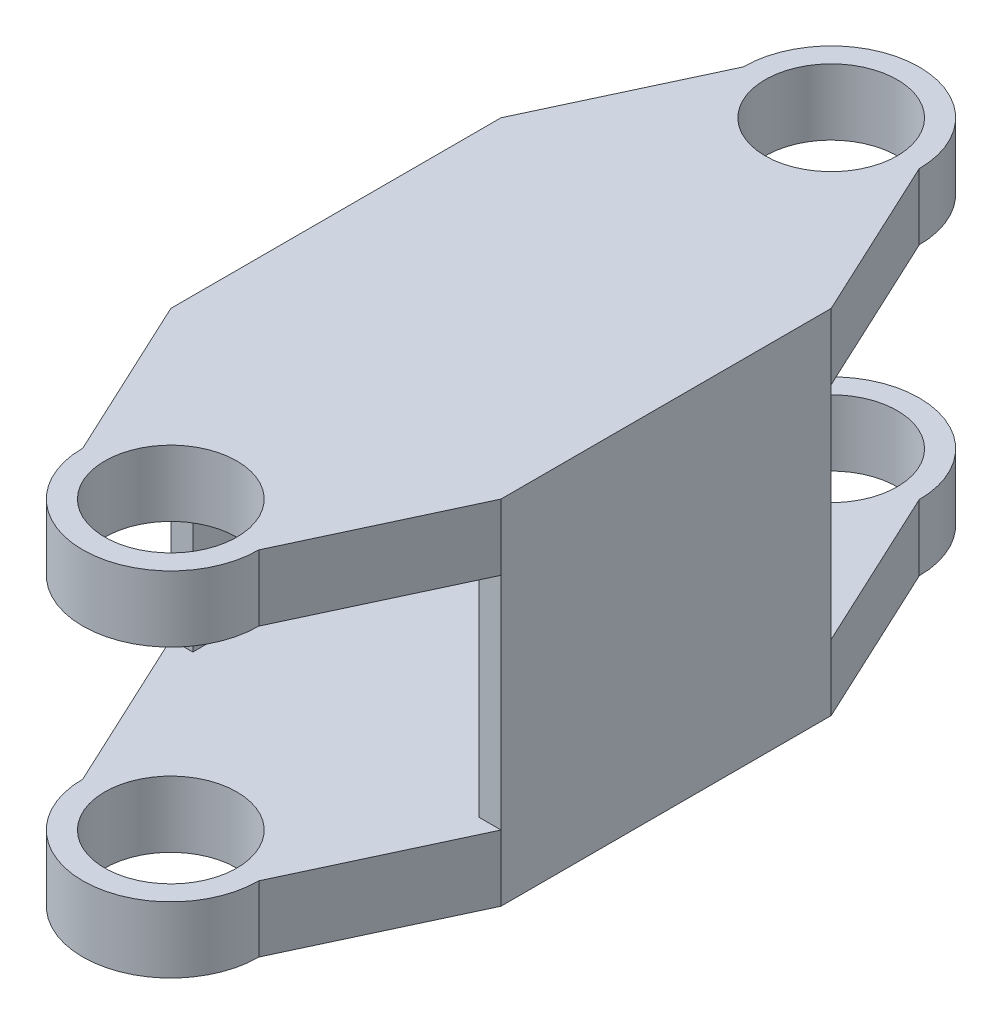
from build123d import *

# Parameters (mm, degrees)
SKETCH1_R           = 3
BOSS_EXTRUDE1_DEPTH = 3
SKETCH5_W           = 1
SKETCH5_H           = 15
SKETCH4_W           = 1
SKETCH4_H           = 15
SKETCH7_W           = 1
SKETCH7_H           = 15
SKETCH6_W           = 1
SKETCH6_H           = 15


with BuildPart() as part:
    # Sketch1 → Boss-Extrude1 (new body)
    with BuildSketch(Plane(origin=(0, 5.01, 0), x_dir=(1, 0, 0), z_dir=(0, 1, 0))):
        with BuildLine():
            Line((-7.5, -7.5), (-7.5, 7.5))
            Line((-7.5, 7.5), (-4, 15))
            ThreePointArc((-4, 15), (0, 19), (4, 15))
            Line((4, 15), (7.5, 7.5))
            Line((7.5, 7.5), (7.5, -7.5))
            Line((7.5, -7.5), (4, -15))
            ThreePointArc((4, -15), (0, -19), (-4, -15))
            Line((-4, -15), (-7.5, -7.5))
        make_face()
        with Locations((0, 15)):
            Circle(SKETCH1_R, mode=Mode.SUBTRACT)
        with Locations((0, -15)):
            Circle(SKETCH1_R, mode=Mode.SUBTRACT)
    boss_extrude1 = extrude(amount=BOSS_EXTRUDE1_DEPTH)

    # Sketch5 → Loft2 section 0
    with BuildSketch(Plane(origin=(0, 0, 0), x_dir=(1, 0, 0), z_dir=(0, 1, 0))):
        with Locations((7, 0)):
            Rectangle(SKETCH5_W, SKETCH5_H)
    # Sketch4 → Loft2 section 1
    with BuildSketch(Plane(origin=(0, 5.01, 0), x_dir=(1, 0, 0), z_dir=(0, 1, 0))):
        with Locations((7, 0)):
            Rectangle(SKETCH4_W, SKETCH4_H)
    loft2 = loft()

    # Sketch7 → Loft3 section 0
    with BuildSketch(Plane(origin=(0, 0, 0), x_dir=(1, 0, 0), z_dir=(0, 1, 0))):
        with Locations((-7, 0)):
            Rectangle(SKETCH7_W, SKETCH7_H)
    # Sketch6 → Loft3 section 1
    with BuildSketch(Plane(origin=(0, 5.01, 0), x_dir=(1, 0, 0), z_dir=(0, 1, 0))):
        with Locations((-7, 0)):
            Rectangle(SKETCH6_W, SKETCH6_H)
    loft3 = loft()

    # Mirror2: Boss-Extrude1, Loft2, Loft3 across plane
    add(boss_extrude1.mirror(Plane.ZX))
    add(loft2.mirror(Plane.ZX))
    add(loft3.mirror(Plane.ZX))


solid = part.part
